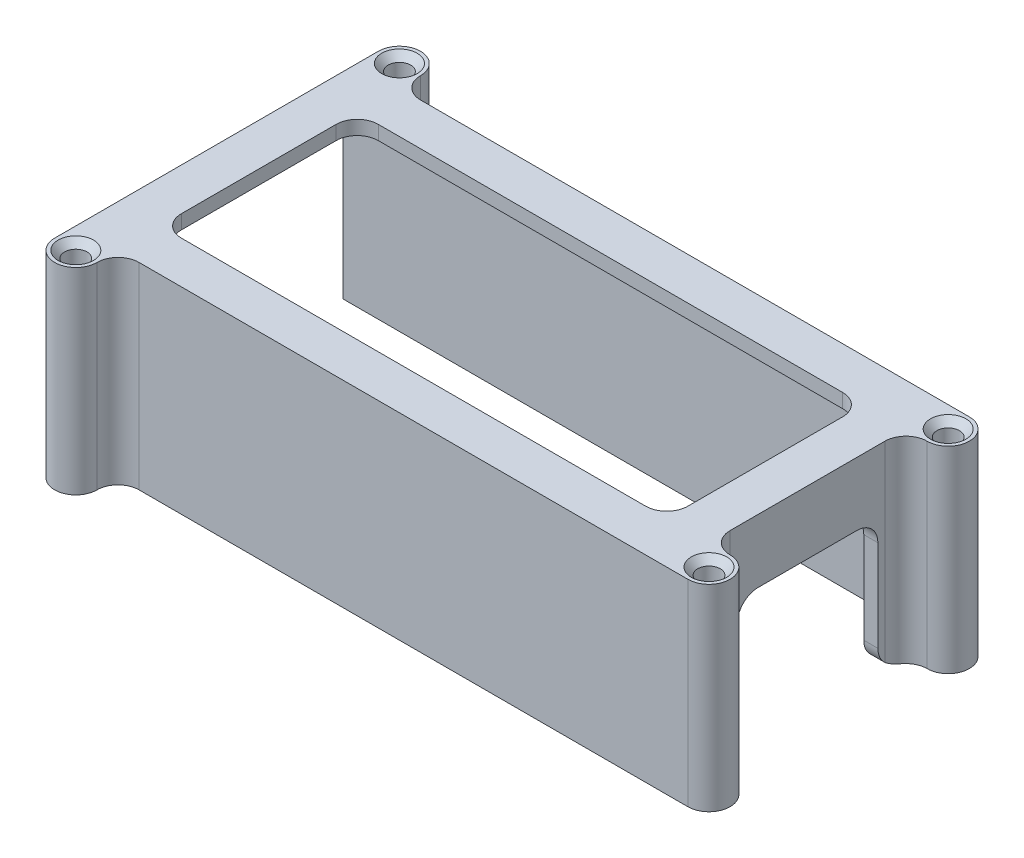
from build123d import *

# Parameters (mm, degrees)
SKETCH1_W           = 133.35
SKETCH1_H           = 63.5
SKETCH1_W_2         = 127
SKETCH1_H_2         = 57.15
BOSS_EXTRUDE1_DEPTH = 41.275
SKETCH2_W           = 31.75
SKETCH2_H           = 60.325
CUT_EXTRUDE1_DEPTH  = 134.35
SKETCH3_W           = 133.35
SKETCH3_H           = 63.5
SKETCH3_W_2         = 114.3
SKETCH3_H_2         = 44.45
BOSS_EXTRUDE2_DEPTH = 3.175
BOSS_EXTRUDE3_DEPTH = 44.45
SKETCH6_R           = 2.54
BOSS_EXTRUDE4_DEPTH = 44.45
CUT_EXTRUDE2_DEPTH  = 4.175
FILLET1_R           = 1.5875
FILLET2_R           = 4.7625


with BuildPart() as part:
    # Sketch1 → Boss-Extrude1 (new body)
    with BuildSketch(Plane(origin=(0, 0, 0), x_dir=(1, 0, 0), z_dir=(0, 1, 0))):
        Rectangle(SKETCH1_W, SKETCH1_H)
        Rectangle(SKETCH1_W_2, SKETCH1_H_2, mode=Mode.SUBTRACT)
    extrude(amount=BOSS_EXTRUDE1_DEPTH)

    # Sketch2 → Cut-Extrude1 (cut, through all)
    with BuildSketch(Plane.ZY.offset(66.675)):
        Rectangle(SKETCH2_W, SKETCH2_H)
    extrude(amount=-CUT_EXTRUDE1_DEPTH, mode=Mode.SUBTRACT)

    # Sketch3 → Boss-Extrude2 (add)
    with BuildSketch(Plane(origin=(0, 41.275, 0), x_dir=(1, 0, 0), z_dir=(0, 1, 0))):
        Rectangle(SKETCH3_W, SKETCH3_H)
        Rectangle(SKETCH3_W_2, SKETCH3_H_2, mode=Mode.SUBTRACT)
    extrude(amount=BOSS_EXTRUDE2_DEPTH)

    # Sketch4 → Boss-Extrude3 (add)
    with BuildSketch(Plane(origin=(0, 44.45, 0), x_dir=(1, 0, 0), z_dir=(0, 1, 0))):
        with BuildLine():
            Line((71.4375, 31.75), (66.675, 31.75))
            Line((66.675, 31.75), (66.675, 17.4625))
            ThreePointArc((66.675, 17.4625), (68.069903955, 20.830096045), (71.4375, 22.225))
            ThreePointArc((71.4375, 22.225), (76.2, 26.9875), (71.4375, 31.75))
        make_face()
    boss_extrude3 = extrude(amount=-BOSS_EXTRUDE3_DEPTH)

    # Sketch5 → Cut-Revolve1 (revolve, cut)
    with BuildSketch(Plane.YZ.offset(71.4375)):
        Polygon((0, -29.5275), (42.8625, -29.5275), (44.45, -30.982175739), (44.45, -26.9875), (0, -26.9875), align=None)
    cut_revolve1 = revolve(axis=Axis((71.4375, 44.45, -26.9875), (0, -1, 0)), mode=Mode.SUBTRACT)

    # Sketch6 → Boss-Extrude4 (add)
    with BuildSketch(Plane(origin=(0, 44.45, 0), x_dir=(1, 0, 0), z_dir=(0, 1, 0))):
        with BuildLine():
            Line((-66.675, 36.5125), (-66.675, 31.75))
            Line((-66.675, 31.75), (-52.3875, 31.75))
            ThreePointArc((-52.3875, 31.75), (-55.755096045, 33.144903955), (-57.15, 36.5125))
            ThreePointArc((-57.15, 36.5125), (-61.9125, 41.275), (-66.675, 36.5125))
        make_face()
        with Locations((-61.9125, 36.5125)):
            Circle(SKETCH6_R, mode=Mode.SUBTRACT)
    boss_extrude4 = extrude(amount=-BOSS_EXTRUDE4_DEPTH)

    # Sketch7 → Cut-Revolve2 (revolve, cut)
    with BuildSketch(Plane(origin=(-61.9125, 0, 0), x_dir=(0, 1, 0), z_dir=(-1, 0, 0))):
        Polygon((42.8625, 39.0525), (44.45, 40.507175739), (44.45, 36.5125), (42.8625, 36.5125), align=None)
    cut_revolve2 = revolve(axis=Axis((-61.9125, 42.8625, -36.5125), (0, -1, 0)), mode=Mode.SUBTRACT)

    # Mirror1: Boss-Extrude3, Cut-Revolve1, Boss-Extrude4, Cut-Revolve2 across plane
    add(boss_extrude3.mirror(Plane.XY))
    add(cut_revolve1.mirror(Plane.XY), mode=Mode.SUBTRACT)
    add(boss_extrude4.mirror(Plane.XY))
    add(cut_revolve2.mirror(Plane.XY), mode=Mode.SUBTRACT)

    # Sketch8 → Cut-Extrude2 (cut, through all)
    with BuildSketch(Plane(origin=(-63.5, 0, 0), x_dir=(0, 0, -1), z_dir=(1, 0, 0))):
        Polygon((-15.875, 0), (-15.875, 30.1625), (15.875, 30.1625), (15.875, 0), (28.575, 0), (28.575, 41.275), (-28.575, 41.275), (-28.575, 0), align=None)
    extrude(amount=-CUT_EXTRUDE2_DEPTH, mode=Mode.SUBTRACT)

    # Fillet1
    fillet1_edges = [part.edges().sort_by_distance(p)[0] for p in [
        (63.5, 20.6375, 28.575),
        (63.5, 20.6375, -28.575),
        (63.5, 41.275, 0),
        (-1.5875, 41.275, -28.575),
        (-1.5875, 41.275, 28.575),
    ]]
    fillet(fillet1_edges, radius=FILLET1_R)

    # Fillet2
    fillet2_edges = [part.edges().sort_by_distance(p)[0] for p in [
        (65.0875, 0, 15.875),
        (65.0875, 30.1625, 15.875),
        (65.0875, 0, -15.875),
        (65.0875, 30.1625, -15.875),
        (-57.15, 42.8625, 22.225),
        (57.15, 42.8625, 22.225),
        (57.15, 42.8625, -22.225),
        (-57.15, 42.8625, -22.225),
    ]]
    fillet(fillet2_edges, radius=FILLET2_R)


solid = part.part
